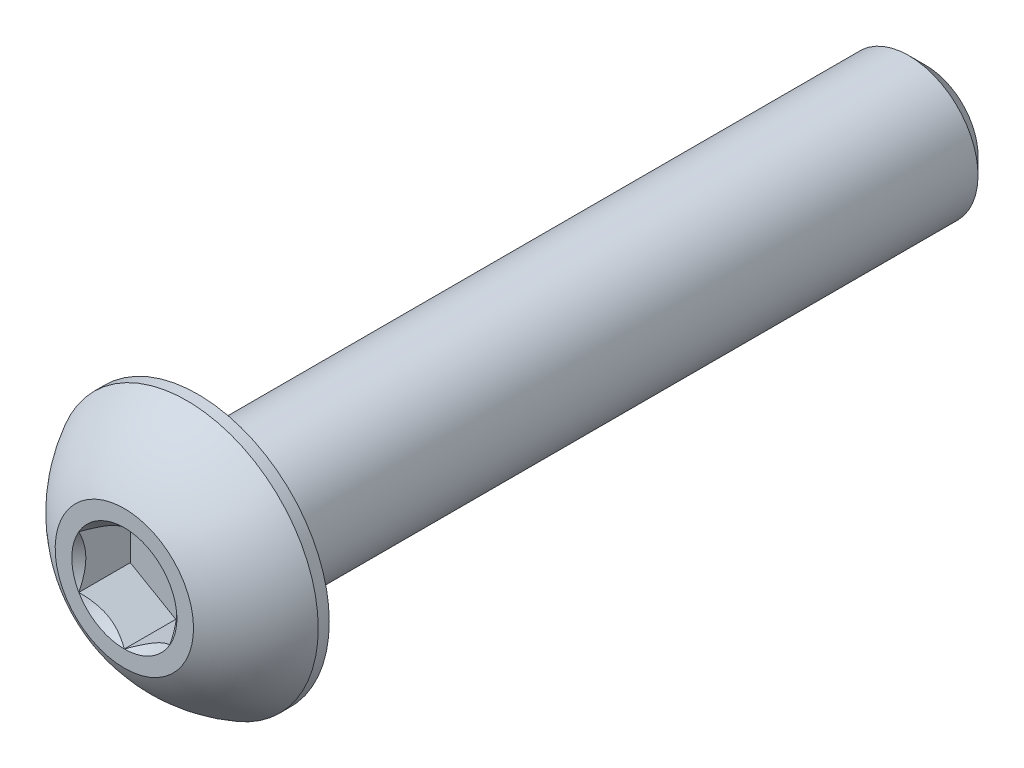
from build123d import *

# Parameters (mm, degrees)
SKETCH1_W          = 25.4
SKETCH1_H          = 2.413
CHAMFER1_SIZE      = 0.5953125
CUT_EXTRUDE2_DEPTH = 1.79578
SKETCH6_R          = 1.833087105
CUT_EXTRUDE3_DEPTH = 1.79578
CUT_EXTRUDE3_TAPER = 45


with BuildPart() as part:
    # Sketch1 → Revolve1 (revolve)
    with BuildSketch(Plane(origin=(0, 0, 0), x_dir=(0, 0, -1), z_dir=(1, 0, 0))):
        with Locations((15.2654, 1.2065)):
            Rectangle(SKETCH1_W, SKETCH1_H)
    revolve(axis=Axis((0, 0, -27.9654), (0, 0, 1)))

    # Chamfer1
    chamfer1_edges = [part.edges().sort_by_distance(p)[0] for p in [
        (0, -2.413, -27.9654),
    ]]
    chamfer(chamfer1_edges, length=CHAMFER1_SIZE)

    # Sketch7 → Revolve2 (revolve)
    with BuildSketch(Plane(origin=(0, 0, 0), x_dir=(0, 0, -1), z_dir=(1, 0, 0))):
        with BuildLine():
            Line((2.18059, 4.5847), (2.5654, 4.5847))
            Line((2.5654, 4.5847), (2.5654, 0))
            Line((2.5654, 0), (0, 0))
            Line((0, 0), (0, 2.413))
            ThreePointArc((0, 2.413), (0.925030326, 3.664791196), (2.18059, 4.5847))
        make_face()
    revolve(axis=Axis((0, 0, 0), (0, 0, -1)))

    # Sketch5 → Cut-Extrude2 (cut)
    with BuildSketch(Plane.XY):
        Polygon((1.5875, -0.916543552), (1.5875, 0.916543552), (0, 1.833087105), (-1.5875, 0.916543552), (-1.5875, -0.916543552), (0, -1.833087105), align=None)
    extrude(amount=-CUT_EXTRUDE2_DEPTH, mode=Mode.SUBTRACT)

    # Sketch6 → Cut-Extrude3 (cut)
    with BuildSketch(Plane.XY):
        Circle(SKETCH6_R)
    extrude(amount=-CUT_EXTRUDE3_DEPTH, taper=CUT_EXTRUDE3_TAPER, mode=Mode.SUBTRACT)


solid = part.part
